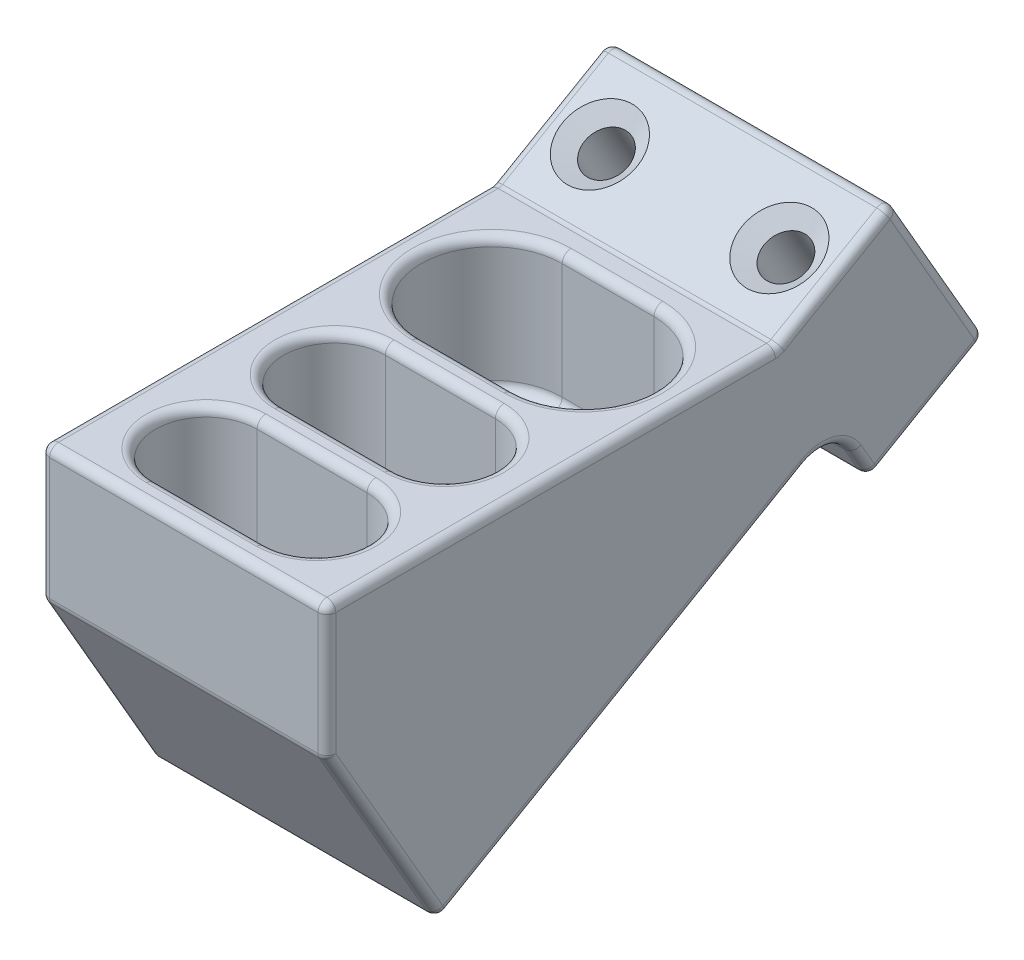
from build123d import *

# Parameters (mm, degrees)
SKETCH1_W                                         = 32.19375
SKETCH1_H                                         = 50.735
BOSS_EXTRUDE1_DEPTH                               = 15
BOSS_EXTRUDE2_START                               = -16.096875
BOSS_EXTRUDE2_DEPTH                               = 32.19375
FILLET2_R                                         = 4
FILLET1_R                                         = 1
CSK_FOR_8_FLAT_HEAD_MACHINE_SCREW_100_D           = 4.9149
CSK_FOR_8_FLAT_HEAD_MACHINE_SCREW_100_CSINK_D     = 8.4328
CSK_FOR_8_FLAT_HEAD_MACHINE_SCREW_100_CSINK_ANGLE = 100
CSK_FOR_8_FLAT_HEAD_MACHINE_SCREW_2_D             = 4.9149
CSK_FOR_8_FLAT_HEAD_MACHINE_SCREW_2_CSINK_D       = 8.4328
CSK_FOR_8_FLAT_HEAD_MACHINE_SCREW_2_CSINK_ANGLE   = 100
FILLET3_R                                         = 1


with BuildPart() as part:
    # Sketch1 → Boss-Extrude1 (new body)
    with BuildSketch(Plane(origin=(0, 0, 0), x_dir=(1, 0, 0), z_dir=(0, 1, 0))):
        with Locations((0, -14.43)):
            Rectangle(SKETCH1_W, SKETCH1_H)
        with BuildLine():
            Line((-5.159375, 7.9375), (5.159375, 7.9375))
            ThreePointArc((5.159375, 7.9375), (13.096875, 0), (5.159375, -7.9375))
            Line((5.159375, -7.9375), (-5.159375, -7.9375))
            ThreePointArc((-5.159375, -7.9375), (-13.096875, 0), (-5.159375, 7.9375))
        make_face(mode=Mode.SUBTRACT)
        with BuildLine():
            Line((-6.19125, -10.9375), (6.19125, -10.9375))
            ThreePointArc((6.19125, -10.9375), (11.90625, -16.6525), (6.19125, -22.3675))
            Line((6.19125, -22.3675), (-6.19125, -22.3675))
            ThreePointArc((-6.19125, -22.3675), (-11.90625, -16.6525), (-6.19125, -10.9375))
        make_face(mode=Mode.SUBTRACT)
        with BuildLine():
            Line((-6.19125, -25.3675), (6.19125, -25.3675))
            ThreePointArc((6.19125, -25.3675), (11.90625, -31.0825), (6.19125, -36.7975))
            Line((6.19125, -36.7975), (-6.19125, -36.7975))
            ThreePointArc((-6.19125, -36.7975), (-11.90625, -31.0825), (-6.19125, -25.3675))
        make_face(mode=Mode.SUBTRACT)
    extrude(amount=-BOSS_EXTRUDE1_DEPTH)

    # Sketch2 → Boss-Extrude2 (add)
    with BuildSketch(Plane(origin=(0, 0, 0), x_dir=(0, 0, -1), z_dir=(1, 0, 0)).offset(BOSS_EXTRUDE2_START)):
        Polygon((10.9375, -15), (-39.7975, -15), (-27.11375, -36.968899431), align=None)
        Polygon((10.9375, 0), (10.9375, -15), (17.432690528, -11.25), (21.432690528, -18.17820323), (34.423071585, -10.67820323), (23.927881057, 7.5), align=None)
    extrude(amount=BOSS_EXTRUDE2_DEPTH)

    # Fillet2
    fillet2_edges = [part.edges().sort_by_distance(p)[0] for p in [
        (0, -11.25, -17.432690528),
    ]]
    fillet(fillet2_edges, radius=FILLET2_R)

    # Fillet1
    fillet1_edges = [part.edges().sort_by_distance(p)[0] for p in [
        (0, -15, 39.7975),
        (-13.096875, 0, 0),
        (0, 0, 7.9375),
        (13.096875, 0, 0),
        (0, 0, -7.9375),
        (-11.90625, 0, 16.6525),
        (0, 0, 22.3675),
        (11.90625, 0, 16.6525),
        (0, 0, 10.9375),
        (-11.90625, 0, 31.0825),
        (0, 0, 36.7975),
        (11.90625, 0, 31.0825),
        (0, 0, 25.3675),
        (16.096875, 0, 14.43),
        (0, 0, 39.7975),
        (16.096875, -25.984449715, 33.455625),
        (0, -36.968899431, 27.11375),
        (-16.096875, 0, 14.43),
        (-16.096875, -25.984449715, 33.455625),
        (0, 0, -10.9375),
        (-16.096875, 3.75, -17.432690528),
        (-16.096875, -1.589101615, -29.175476321),
        (-16.096875, -14.42820323, -27.927881057),
        (-16.096875, -16.446152423, -20.432690528),
        (16.096875, 3.75, -17.432690528),
        (0, 7.5, -23.927881057),
        (16.096875, -1.589101615, -29.175476321),
        (0, -10.67820323, -34.423071585),
        (16.096875, -14.42820323, -27.927881057),
        (0, -18.17820323, -21.432690528),
        (16.096875, -16.446152423, -20.432690528),
        (16.096875, -7.5, 39.7975),
        (-16.096875, -7.5, 39.7975),
        (-16.096875, -25.109449715, 6.572580543),
        (16.096875, -25.109449715, 6.572580543),
        (-16.096875, -12.85039831, -17.003865094),
        (16.096875, -12.85039831, -17.003865094),
    ]]
    fillet(fillet1_edges, radius=FILLET1_R)

    # CSK for #8 Flat Head Machine Screw (100)1 (through all)
    with Locations(Plane(origin=(-10.096875, 3.566987298, -17.11570323), x_dir=(0, -0.5, 0.866025404), z_dir=(0, 0.866025404, 0.5))):
        with Locations((0, 0)):
            CounterSinkHole(CSK_FOR_8_FLAT_HEAD_MACHINE_SCREW_100_D / 2, CSK_FOR_8_FLAT_HEAD_MACHINE_SCREW_100_CSINK_D / 2, counter_sink_angle=CSK_FOR_8_FLAT_HEAD_MACHINE_SCREW_100_CSINK_ANGLE)

    # CSK for _8 Flat Head Machine Screw _ 2 (through all)
    with Locations(Plane(origin=(10.096875, 3.566987298, -17.11570323), x_dir=(0, -0.500000175, 0.866025303), z_dir=(0, 0.866025303, 0.500000175))):
        with Locations((0, 0)):
            CounterSinkHole(CSK_FOR_8_FLAT_HEAD_MACHINE_SCREW_2_D / 2, CSK_FOR_8_FLAT_HEAD_MACHINE_SCREW_2_CSINK_D / 2, counter_sink_angle=CSK_FOR_8_FLAT_HEAD_MACHINE_SCREW_2_CSINK_ANGLE)

    # Fillet3
    fillet3_edges = [part.edges().sort_by_distance(p)[0] for p in [
        (-13.096875, -15, 0),
        (0, -15, -7.9375),
        (13.096875, -15, 0),
        (0, -15, 7.9375),
        (-11.90625, -15, 16.6525),
        (0, -15, 10.9375),
        (11.90625, -15, 16.6525),
        (0, -15, 22.3675),
        (-11.90625, -15, 31.0825),
        (0, -15, 25.3675),
        (11.90625, -15, 31.0825),
        (0, -15, 36.7975),
    ]]
    fillet(fillet3_edges, radius=FILLET3_R)


solid = part.part
